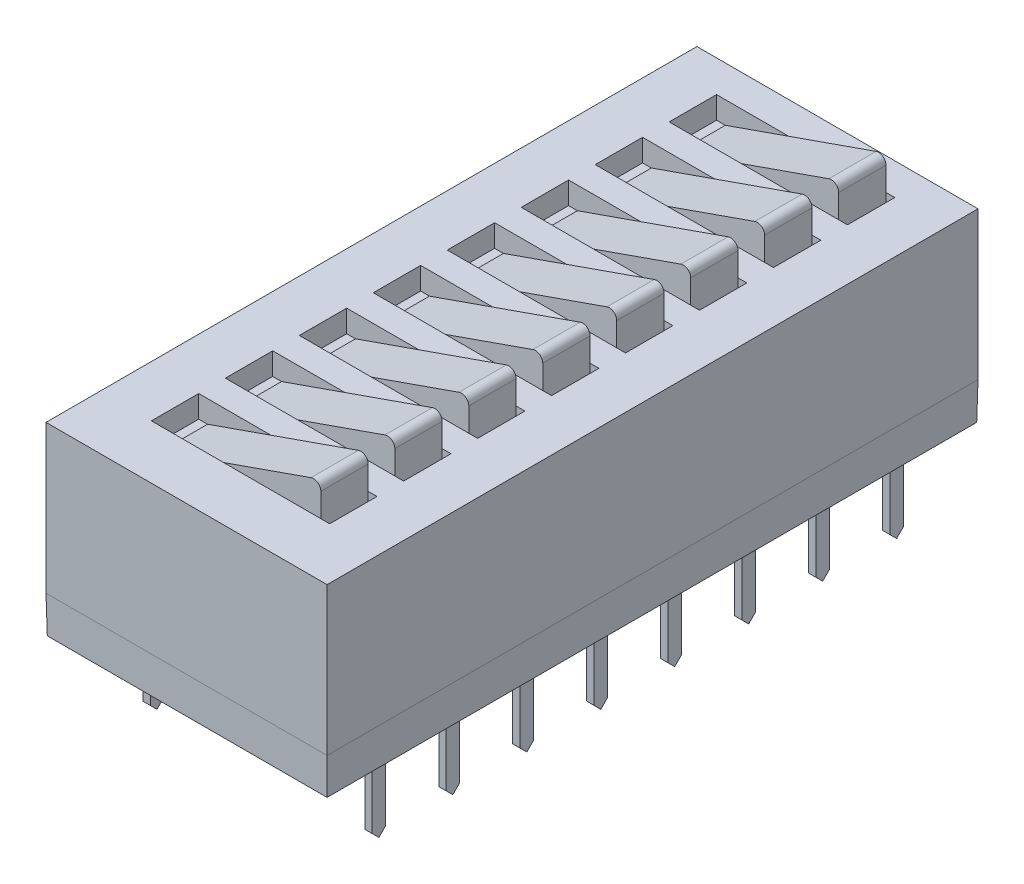
from build123d import *

# Parameters (mm, degrees)
SKETCH1_W                = 22.352
SKETCH1_H                = 9.652
BASE_EXTRUDE_DEPTH       = 6.35
CHAMFER1_SIZE2           = 0.022167932
CHAMFER1_SIZE            = 1.27
BOSS_EXTRUDE_THIN1_DEPTH = 0.635
CUT_EXTRUDE1_DEPTH       = 2.143
CUT_EXTRUDE2_DEPTH       = 2.143
LPATTERN2_COUNT          = 8
LPATTERN2_PITCH          = 2.54
MIRROR1_COPY_1_DEPTH     = 0.635
MIRROR1_COPY_2_DEPTH     = 0.635
MIRROR1_COPY_3_DEPTH     = 0.635
MIRROR1_COPY_4_DEPTH     = 0.635
MIRROR1_COPY_5_DEPTH     = 0.635
MIRROR1_COPY_6_DEPTH     = 0.635
MIRROR1_COPY_7_DEPTH     = 0.635
MIRROR1_COPY_8_DEPTH     = 2.143
MIRROR1_COPY_9_DEPTH     = 2.143
MIRROR1_COPY_10_DEPTH    = 2.143
MIRROR1_COPY_11_DEPTH    = 2.143
MIRROR1_COPY_12_DEPTH    = 2.143
MIRROR1_COPY_13_DEPTH    = 2.143
MIRROR1_COPY_14_DEPTH    = 2.143
MIRROR1_COPY_15_DEPTH    = 2.143
MIRROR1_COPY_16_DEPTH    = 2.143
MIRROR1_COPY_17_DEPTH    = 2.143
MIRROR1_COPY_18_DEPTH    = 2.143
MIRROR1_COPY_19_DEPTH    = 2.143
MIRROR1_COPY_20_DEPTH    = 2.143
MIRROR1_COPY_21_DEPTH    = 2.143
SKETCH6_W                = 1.6256
SKETCH6_H                = 6.1214
CUT_EXTRUDE3_DEPTH       = 0.762
BOSS_EXTRUDE1_DEPTH      = 1.6256
LPATTERN3_COUNT          = 8
LPATTERN3_PITCH          = 2.54


with BuildPart() as part:
    # Sketch1 → Base-Extrude (new body)
    with BuildSketch(Plane(origin=(0, 0.381, 0), x_dir=(0, 0, -1), z_dir=(0, 1, 0))):
        with Locations((-9.271, -3.81)):
            Rectangle(SKETCH1_W, SKETCH1_H)
    extrude(amount=BASE_EXTRUDE_DEPTH)

    # Chamfer1
    chamfer1_edges = [part.edges().sort_by_distance(p)[0] for p in [
        (8.636, 0.381, 9.271),
        (3.81, 0.381, 20.447),
        (-1.016, 0.381, 9.271),
        (3.81, 0.381, -1.905),
    ]]
    chamfer(chamfer1_edges, length=CHAMFER1_SIZE, length2=CHAMFER1_SIZE2)

    # Sketch3 → Boss-Extrude-Thin1 (add, symmetric)
    with BuildSketch(Plane(origin=(10.541, 0, 0), x_dir=(-1, 0, 0), z_dir=(0, 0, -1))):
        with BuildLine():
            Line((9.271, 1.8796), (10.033, 1.8796))
            ThreePointArc((10.033, 1.8796), (10.302407684, 1.768007684), (10.414, 1.4986))
            Line((10.414, 1.4986), (10.414, -2.5654))
            Line((10.414, -2.5654), (10.668, -2.5654))
            Line((10.668, -2.5654), (10.668, 1.4986))
            ThreePointArc((10.668, 1.4986), (10.482012806, 1.947612806), (10.033, 2.1336))
            Line((10.033, 2.1336), (9.271, 2.1336))
            Line((9.271, 2.1336), (9.271, 1.8796))
        make_face()
    boss_extrude_thin1 = extrude(amount=BOSS_EXTRUDE_THIN1_DEPTH, both=True)

    # Sketch4 → Cut-Extrude1 (cut, through all)
    with BuildSketch(Plane(origin=(0.127, 0, 0), x_dir=(0, 0, -1), z_dir=(1, 0, 0))):
        Polygon((0.635, -2.5654), (0, -2.5654), (0.2286, -2.3368), (0.2286, -0.0254), (0.635, 0.381), align=None)
    cut_extrude1 = extrude(amount=-CUT_EXTRUDE1_DEPTH, mode=Mode.SUBTRACT)

    # Sketch5 → Cut-Extrude2 (cut, through all)
    with BuildSketch(Plane(origin=(0.127, 0, 0), x_dir=(0, 0, -1), z_dir=(1, 0, 0))):
        Polygon((-0.635, 0.381), (-0.2286, -0.0254), (-0.2286, -2.3368), (0, -2.5654), (-0.635, -2.5654), align=None)
    cut_extrude2 = extrude(amount=-CUT_EXTRUDE2_DEPTH, mode=Mode.SUBTRACT)

    # LPattern2: Boss-Extrude-Thin1, Cut-Extrude1, Cut-Extrude2 ×8
    with Locations(*[(0, 0, i * LPATTERN2_PITCH) for i in range(1, LPATTERN2_COUNT)]):
        add(boss_extrude_thin1)
        add(cut_extrude1, mode=Mode.SUBTRACT)
        add(cut_extrude2, mode=Mode.SUBTRACT)

    # Mirror1: Boss-Extrude-Thin1, Cut-Extrude1, Cut-Extrude2 across plane
    add(boss_extrude_thin1.mirror(Plane.ZY.offset(-3.81)))
    add(cut_extrude1.mirror(Plane.ZY.offset(-3.81)), mode=Mode.SUBTRACT)
    add(cut_extrude2.mirror(Plane.ZY.offset(-3.81)), mode=Mode.SUBTRACT)

    # Mirror1 copy 1 sketch → Mirror1 copy 1 (add, symmetric)
    with BuildSketch(Plane(origin=(-2.921, 0, 2.54), x_dir=(1, 0, 0), z_dir=(0, 0, -1))):
        with BuildLine():
            Line((9.271, -1.8796), (10.033, -1.8796))
            ThreePointArc((10.033, -1.8796), (10.302407684, -1.768007684), (10.414, -1.4986))
            Line((10.414, -1.4986), (10.414, 2.5654))
            Line((10.414, 2.5654), (10.668, 2.5654))
            Line((10.668, 2.5654), (10.668, -1.4986))
            ThreePointArc((10.668, -1.4986), (10.482012806, -1.947612806), (10.033, -2.1336))
            Line((10.033, -2.1336), (9.271, -2.1336))
            Line((9.271, -2.1336), (9.271, -1.8796))
        make_face()
    extrude(amount=MIRROR1_COPY_1_DEPTH, both=True)

    # Mirror1 copy 2 sketch → Mirror1 copy 2 (add, symmetric)
    with BuildSketch(Plane(origin=(-2.921, 0, 5.08), x_dir=(1, 0, 0), z_dir=(0, 0, -1))):
        with BuildLine():
            Line((9.271, -1.8796), (10.033, -1.8796))
            ThreePointArc((10.033, -1.8796), (10.302407684, -1.768007684), (10.414, -1.4986))
            Line((10.414, -1.4986), (10.414, 2.5654))
            Line((10.414, 2.5654), (10.668, 2.5654))
            Line((10.668, 2.5654), (10.668, -1.4986))
            ThreePointArc((10.668, -1.4986), (10.482012806, -1.947612806), (10.033, -2.1336))
            Line((10.033, -2.1336), (9.271, -2.1336))
            Line((9.271, -2.1336), (9.271, -1.8796))
        make_face()
    extrude(amount=MIRROR1_COPY_2_DEPTH, both=True)

    # Mirror1 copy 3 sketch → Mirror1 copy 3 (add, symmetric)
    with BuildSketch(Plane(origin=(-2.921, 0, 7.62), x_dir=(1, 0, 0), z_dir=(0, 0, -1))):
        with BuildLine():
            Line((9.271, -1.8796), (10.033, -1.8796))
            ThreePointArc((10.033, -1.8796), (10.302407684, -1.768007684), (10.414, -1.4986))
            Line((10.414, -1.4986), (10.414, 2.5654))
            Line((10.414, 2.5654), (10.668, 2.5654))
            Line((10.668, 2.5654), (10.668, -1.4986))
            ThreePointArc((10.668, -1.4986), (10.482012806, -1.947612806), (10.033, -2.1336))
            Line((10.033, -2.1336), (9.271, -2.1336))
            Line((9.271, -2.1336), (9.271, -1.8796))
        make_face()
    extrude(amount=MIRROR1_COPY_3_DEPTH, both=True)

    # Mirror1 copy 4 sketch → Mirror1 copy 4 (add, symmetric)
    with BuildSketch(Plane(origin=(-2.921, 0, 10.16), x_dir=(1, 0, 0), z_dir=(0, 0, -1))):
        with BuildLine():
            Line((9.271, -1.8796), (10.033, -1.8796))
            ThreePointArc((10.033, -1.8796), (10.302407684, -1.768007684), (10.414, -1.4986))
            Line((10.414, -1.4986), (10.414, 2.5654))
            Line((10.414, 2.5654), (10.668, 2.5654))
            Line((10.668, 2.5654), (10.668, -1.4986))
            ThreePointArc((10.668, -1.4986), (10.482012806, -1.947612806), (10.033, -2.1336))
            Line((10.033, -2.1336), (9.271, -2.1336))
            Line((9.271, -2.1336), (9.271, -1.8796))
        make_face()
    extrude(amount=MIRROR1_COPY_4_DEPTH, both=True)

    # Mirror1 copy 5 sketch → Mirror1 copy 5 (add, symmetric)
    with BuildSketch(Plane(origin=(-2.921, 0, 12.7), x_dir=(1, 0, 0), z_dir=(0, 0, -1))):
        with BuildLine():
            Line((9.271, -1.8796), (10.033, -1.8796))
            ThreePointArc((10.033, -1.8796), (10.302407684, -1.768007684), (10.414, -1.4986))
            Line((10.414, -1.4986), (10.414, 2.5654))
            Line((10.414, 2.5654), (10.668, 2.5654))
            Line((10.668, 2.5654), (10.668, -1.4986))
            ThreePointArc((10.668, -1.4986), (10.482012806, -1.947612806), (10.033, -2.1336))
            Line((10.033, -2.1336), (9.271, -2.1336))
            Line((9.271, -2.1336), (9.271, -1.8796))
        make_face()
    extrude(amount=MIRROR1_COPY_5_DEPTH, both=True)

    # Mirror1 copy 6 sketch → Mirror1 copy 6 (add, symmetric)
    with BuildSketch(Plane(origin=(-2.921, 0, 15.24), x_dir=(1, 0, 0), z_dir=(0, 0, -1))):
        with BuildLine():
            Line((9.271, -1.8796), (10.033, -1.8796))
            ThreePointArc((10.033, -1.8796), (10.302407684, -1.768007684), (10.414, -1.4986))
            Line((10.414, -1.4986), (10.414, 2.5654))
            Line((10.414, 2.5654), (10.668, 2.5654))
            Line((10.668, 2.5654), (10.668, -1.4986))
            ThreePointArc((10.668, -1.4986), (10.482012806, -1.947612806), (10.033, -2.1336))
            Line((10.033, -2.1336), (9.271, -2.1336))
            Line((9.271, -2.1336), (9.271, -1.8796))
        make_face()
    extrude(amount=MIRROR1_COPY_6_DEPTH, both=True)

    # Mirror1 copy 7 sketch → Mirror1 copy 7 (add, symmetric)
    with BuildSketch(Plane(origin=(-2.921, 0, 17.78), x_dir=(1, 0, 0), z_dir=(0, 0, -1))):
        with BuildLine():
            Line((9.271, -1.8796), (10.033, -1.8796))
            ThreePointArc((10.033, -1.8796), (10.302407684, -1.768007684), (10.414, -1.4986))
            Line((10.414, -1.4986), (10.414, 2.5654))
            Line((10.414, 2.5654), (10.668, 2.5654))
            Line((10.668, 2.5654), (10.668, -1.4986))
            ThreePointArc((10.668, -1.4986), (10.482012806, -1.947612806), (10.033, -2.1336))
            Line((10.033, -2.1336), (9.271, -2.1336))
            Line((9.271, -2.1336), (9.271, -1.8796))
        make_face()
    extrude(amount=MIRROR1_COPY_7_DEPTH, both=True)

    # Mirror1 copy 8 sketch → Mirror1 copy 8 (cut, through all)
    with BuildSketch(Plane(origin=(7.493, 0, 2.54), x_dir=(0, 0, -1), z_dir=(-1, 0, 0))):
        Polygon((0.635, 2.5654), (0, 2.5654), (0.2286, 2.3368), (0.2286, 0.0254), (0.635, -0.381), align=None)
    extrude(amount=-MIRROR1_COPY_8_DEPTH, mode=Mode.SUBTRACT)

    # Mirror1 copy 9 sketch → Mirror1 copy 9 (cut, through all)
    with BuildSketch(Plane(origin=(7.493, 0, 5.08), x_dir=(0, 0, -1), z_dir=(-1, 0, 0))):
        Polygon((0.635, 2.5654), (0, 2.5654), (0.2286, 2.3368), (0.2286, 0.0254), (0.635, -0.381), align=None)
    extrude(amount=-MIRROR1_COPY_9_DEPTH, mode=Mode.SUBTRACT)

    # Mirror1 copy 10 sketch → Mirror1 copy 10 (cut, through all)
    with BuildSketch(Plane(origin=(7.493, 0, 7.62), x_dir=(0, 0, -1), z_dir=(-1, 0, 0))):
        Polygon((0.635, 2.5654), (0, 2.5654), (0.2286, 2.3368), (0.2286, 0.0254), (0.635, -0.381), align=None)
    extrude(amount=-MIRROR1_COPY_10_DEPTH, mode=Mode.SUBTRACT)

    # Mirror1 copy 11 sketch → Mirror1 copy 11 (cut, through all)
    with BuildSketch(Plane(origin=(7.493, 0, 10.16), x_dir=(0, 0, -1), z_dir=(-1, 0, 0))):
        Polygon((0.635, 2.5654), (0, 2.5654), (0.2286, 2.3368), (0.2286, 0.0254), (0.635, -0.381), align=None)
    extrude(amount=-MIRROR1_COPY_11_DEPTH, mode=Mode.SUBTRACT)

    # Mirror1 copy 12 sketch → Mirror1 copy 12 (cut, through all)
    with BuildSketch(Plane(origin=(7.493, 0, 12.7), x_dir=(0, 0, -1), z_dir=(-1, 0, 0))):
        Polygon((0.635, 2.5654), (0, 2.5654), (0.2286, 2.3368), (0.2286, 0.0254), (0.635, -0.381), align=None)
    extrude(amount=-MIRROR1_COPY_12_DEPTH, mode=Mode.SUBTRACT)

    # Mirror1 copy 13 sketch → Mirror1 copy 13 (cut, through all)
    with BuildSketch(Plane(origin=(7.493, 0, 15.24), x_dir=(0, 0, -1), z_dir=(-1, 0, 0))):
        Polygon((0.635, 2.5654), (0, 2.5654), (0.2286, 2.3368), (0.2286, 0.0254), (0.635, -0.381), align=None)
    extrude(amount=-MIRROR1_COPY_13_DEPTH, mode=Mode.SUBTRACT)

    # Mirror1 copy 14 sketch → Mirror1 copy 14 (cut, through all)
    with BuildSketch(Plane(origin=(7.493, 0, 17.78), x_dir=(0, 0, -1), z_dir=(-1, 0, 0))):
        Polygon((0.635, 2.5654), (0, 2.5654), (0.2286, 2.3368), (0.2286, 0.0254), (0.635, -0.381), align=None)
    extrude(amount=-MIRROR1_COPY_14_DEPTH, mode=Mode.SUBTRACT)

    # Mirror1 copy 15 sketch → Mirror1 copy 15 (cut, through all)
    with BuildSketch(Plane(origin=(7.493, 0, 2.54), x_dir=(0, 0, -1), z_dir=(-1, 0, 0))):
        Polygon((-0.635, -0.381), (-0.2286, 0.0254), (-0.2286, 2.3368), (0, 2.5654), (-0.635, 2.5654), align=None)
    extrude(amount=-MIRROR1_COPY_15_DEPTH, mode=Mode.SUBTRACT)

    # Mirror1 copy 16 sketch → Mirror1 copy 16 (cut, through all)
    with BuildSketch(Plane(origin=(7.493, 0, 5.08), x_dir=(0, 0, -1), z_dir=(-1, 0, 0))):
        Polygon((-0.635, -0.381), (-0.2286, 0.0254), (-0.2286, 2.3368), (0, 2.5654), (-0.635, 2.5654), align=None)
    extrude(amount=-MIRROR1_COPY_16_DEPTH, mode=Mode.SUBTRACT)

    # Mirror1 copy 17 sketch → Mirror1 copy 17 (cut, through all)
    with BuildSketch(Plane(origin=(7.493, 0, 7.62), x_dir=(0, 0, -1), z_dir=(-1, 0, 0))):
        Polygon((-0.635, -0.381), (-0.2286, 0.0254), (-0.2286, 2.3368), (0, 2.5654), (-0.635, 2.5654), align=None)
    extrude(amount=-MIRROR1_COPY_17_DEPTH, mode=Mode.SUBTRACT)

    # Mirror1 copy 18 sketch → Mirror1 copy 18 (cut, through all)
    with BuildSketch(Plane(origin=(7.493, 0, 10.16), x_dir=(0, 0, -1), z_dir=(-1, 0, 0))):
        Polygon((-0.635, -0.381), (-0.2286, 0.0254), (-0.2286, 2.3368), (0, 2.5654), (-0.635, 2.5654), align=None)
    extrude(amount=-MIRROR1_COPY_18_DEPTH, mode=Mode.SUBTRACT)

    # Mirror1 copy 19 sketch → Mirror1 copy 19 (cut, through all)
    with BuildSketch(Plane(origin=(7.493, 0, 12.7), x_dir=(0, 0, -1), z_dir=(-1, 0, 0))):
        Polygon((-0.635, -0.381), (-0.2286, 0.0254), (-0.2286, 2.3368), (0, 2.5654), (-0.635, 2.5654), align=None)
    extrude(amount=-MIRROR1_COPY_19_DEPTH, mode=Mode.SUBTRACT)

    # Mirror1 copy 20 sketch → Mirror1 copy 20 (cut, through all)
    with BuildSketch(Plane(origin=(7.493, 0, 15.24), x_dir=(0, 0, -1), z_dir=(-1, 0, 0))):
        Polygon((-0.635, -0.381), (-0.2286, 0.0254), (-0.2286, 2.3368), (0, 2.5654), (-0.635, 2.5654), align=None)
    extrude(amount=-MIRROR1_COPY_20_DEPTH, mode=Mode.SUBTRACT)

    # Mirror1 copy 21 sketch → Mirror1 copy 21 (cut, through all)
    with BuildSketch(Plane(origin=(7.493, 0, 17.78), x_dir=(0, 0, -1), z_dir=(-1, 0, 0))):
        Polygon((-0.635, -0.381), (-0.2286, 0.0254), (-0.2286, 2.3368), (0, 2.5654), (-0.635, 2.5654), align=None)
    extrude(amount=-MIRROR1_COPY_21_DEPTH, mode=Mode.SUBTRACT)

    # Sketch6 → Cut-Extrude3 (cut)
    with BuildSketch(Plane(origin=(-4.3561, 6.731, -3.2639), x_dir=(0, 0, -1), z_dir=(0, 1, 0))):
        with Locations((-3.2639, -8.1661)):
            Rectangle(SKETCH6_W, SKETCH6_H)
    cut_extrude3 = extrude(amount=-CUT_EXTRUDE3_DEPTH, mode=Mode.SUBTRACT)

    # Sketch7 → Boss-Extrude1 (add)
    with BuildSketch(Plane.XY.offset(-0.8128)):
        with BuildLine():
            Line((1.051989902, 5.969), (6.230059443, 7.782334164))
            ThreePointArc((6.230059443, 7.782334164), (6.460966781, 7.749779505), (6.568010098, 7.542608722))
            Line((6.568010098, 7.542608722), (6.568010098, 5.969))
            Line((6.568010098, 5.969), (1.051989902, 5.969))
        make_face()
    boss_extrude1 = extrude(amount=BOSS_EXTRUDE1_DEPTH)

    # LPattern3: Cut-Extrude3, Boss-Extrude1 ×8
    with Locations(*[(0, 0, i * LPATTERN3_PITCH) for i in range(1, LPATTERN3_COUNT)]):
        add(cut_extrude3, mode=Mode.SUBTRACT)
        add(boss_extrude1)


solid = part.part
